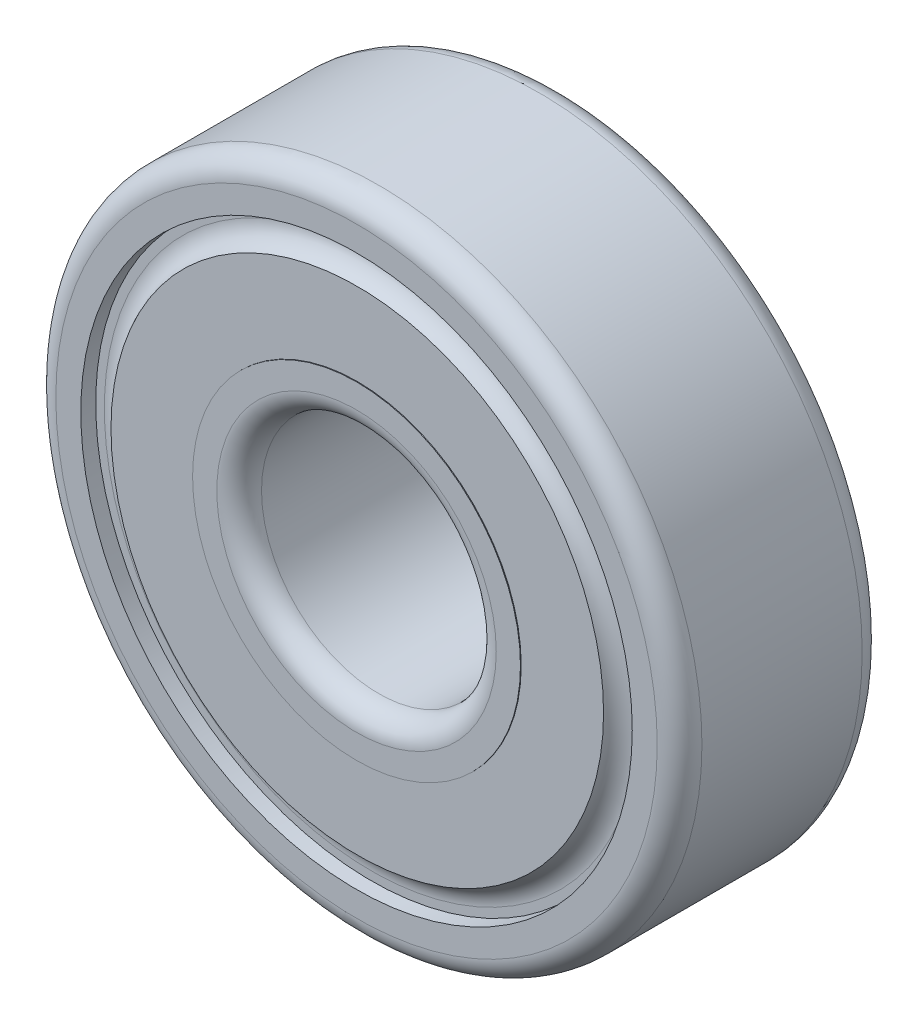
from build123d import *


with BuildPart() as part:
    # Sketch1 → Revolve1 (revolve)
    with BuildSketch(Plane(origin=(0, 0, 0), x_dir=(1, 0, 0), z_dir=(0, 1, 0))):
        with BuildLine():
            Line((4.0005, 2.7305), (4.0005, -2.7305))
            ThreePointArc((4.0005, -2.7305), (4.223684633, -3.269315367), (4.7625, -3.4925))
            Line((4.7625, -3.4925), (5.588, -3.4925))
            Line((5.588, -3.4925), (5.588, -3.4671))
            Line((5.588, -3.4671), (8.3947, -3.4671))
            ThreePointArc((8.3947, -3.4671), (8.674827163, -3.116600484), (9.103628515, -2.9845))
            Line((9.103628515, -2.9845), (9.398, -2.9845))
            Line((9.398, -2.9845), (9.398, -3.4925))
            Line((9.398, -3.4925), (10.2489, -3.4925))
            ThreePointArc((10.2489, -3.4925), (10.787715367, -3.269315367), (11.0109, -2.7305))
            Line((11.0109, -2.7305), (11.0109, 2.7305))
            ThreePointArc((11.0109, 2.7305), (10.787715367, 3.269315367), (10.2489, 3.4925))
            Line((10.2489, 3.4925), (9.398, 3.4925))
            Line((9.398, 3.4925), (9.398, 2.9845))
            Line((9.398, 2.9845), (8.3947, 2.9845))
            Line((8.3947, 2.9845), (8.3947, 3.4671))
            Line((8.3947, 3.4671), (5.588, 3.4671))
            Line((5.588, 3.4671), (5.588, 3.4925))
            Line((5.588, 3.4925), (4.7625, 3.4925))
            ThreePointArc((4.7625, 3.4925), (4.223684633, 3.269315367), (4.0005, 2.7305))
        make_face()
    revolve(axis=Axis((0, 0, -3.495313106), (0, 0, 1)))


solid = part.part
